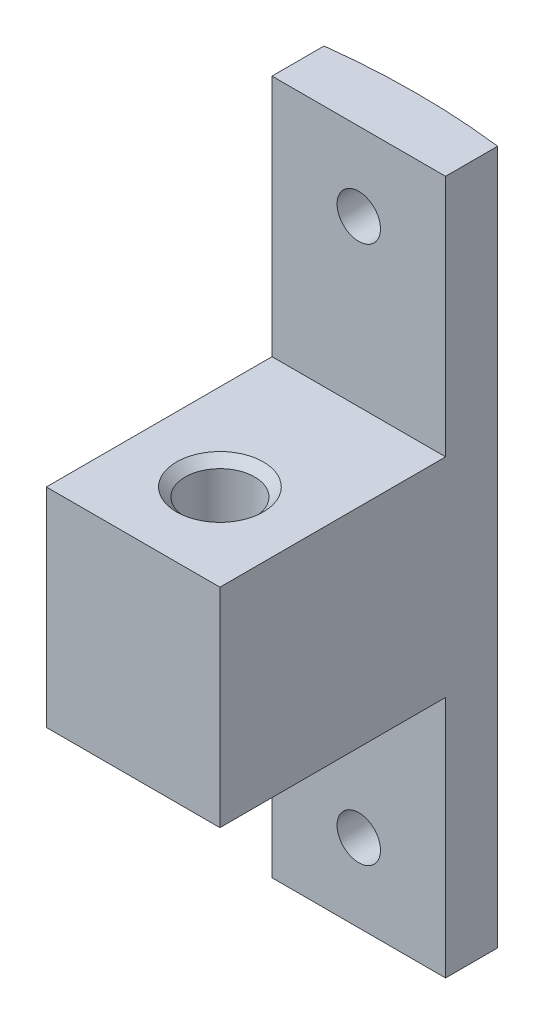
from build123d import *

# Parameters (mm, degrees)
BOSS_EXTRU_1_DEPTH         = 20
ESQUISSE2_W                = 10
ESQUISSE2_H                = 13
BOSS_EXTRU_2_DEPTH         = 6
D_GAGEMENT_M41_D           = 4
D_GAGEMENT_M41_CSINK_D     = 5
D_GAGEMENT_M41_CSINK_ANGLE = 90
D_GAGEMENT_M2_51_D         = 2.5


with BuildPart() as part:
    # Esquisse1 → Boss.-Extru.1 (new body)
    with BuildSketch(Plane(origin=(0, 0, 0), x_dir=(1, 0, 0), z_dir=(0, 1, 0))):
        with BuildLine():
            Line((0, 0), (10, 0))
            Line((10, 0), (10, 3))
            ThreePointArc((10, 3), (5, 3.306020101), (0, 3))
            Line((0, 3), (0, 0))
        make_face()
    boss_extru_1 = extrude(amount=BOSS_EXTRU_1_DEPTH)

    # Esquisse2 → Boss.-Extru.2 (add)
    with BuildSketch(Plane.XZ):
        with Locations((5, 6.5)):
            Rectangle(ESQUISSE2_W, ESQUISSE2_H)
    boss_extru_2 = extrude(amount=-BOSS_EXTRU_2_DEPTH)

    # Dégagement M41 (through all)
    with Locations(Plane(origin=(0, 6, 0), x_dir=(1, 0, 0), z_dir=(0, 1, 0))):
        with Locations((5, -8)):
            d_gagement_m41 = CounterSinkHole(D_GAGEMENT_M41_D / 2, D_GAGEMENT_M41_CSINK_D / 2, counter_sink_angle=D_GAGEMENT_M41_CSINK_ANGLE)

    # Dégagement M2.51 (through all)
    with Locations(Plane(origin=(5, 15.5, -3.306020101), x_dir=(-1, 0, 0), z_dir=(0, 0, -1))):
        with Locations((0, 0)):
            d_gagement_m2_51 = Hole(D_GAGEMENT_M2_51_D / 2)

    # Symétrie1: Boss.-Extru.1, Boss.-Extru.2, Dégagement M41, Dégagement M2.51 across plane
    add(boss_extru_1.mirror(Plane(origin=(5, 0, 37.693979899), x_dir=(0, 0, 1), z_dir=(0, -1, 0))))
    add(boss_extru_2.mirror(Plane(origin=(5, 0, 37.693979899), x_dir=(0, 0, 1), z_dir=(0, -1, 0))))
    add(d_gagement_m41.mirror(Plane(origin=(5, 0, 37.693979899), x_dir=(0, 0, 1), z_dir=(0, -1, 0))), mode=Mode.SUBTRACT)
    add(d_gagement_m2_51.mirror(Plane(origin=(5, 0, 37.693979899), x_dir=(0, 0, 1), z_dir=(0, -1, 0))), mode=Mode.SUBTRACT)


solid = part.part
